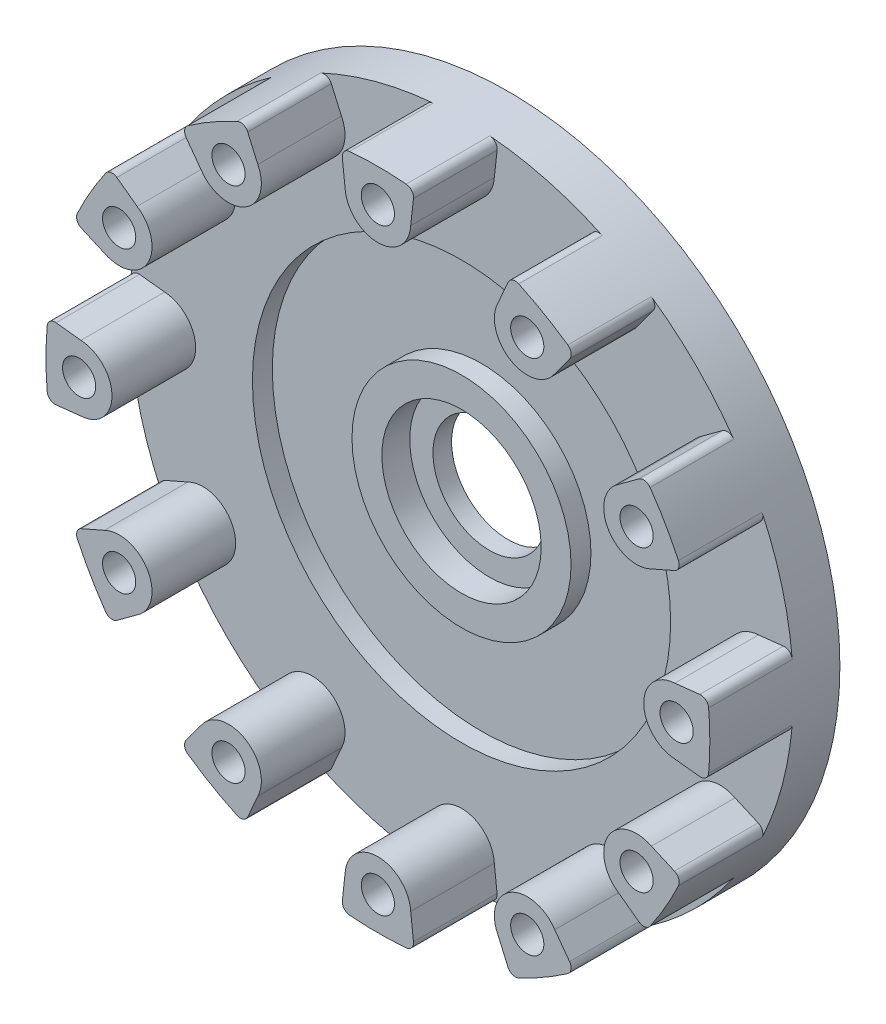
from build123d import *

# Parameters (mm, degrees)
SKETCH1_R           = 50
BOSS_EXTRUDE1_DEPTH = 7
SKETCH2_R           = 2.5
BOSS_EXTRUDE2_DEPTH = 12.6
CIRPATTERN1_COUNT   = 12
SKETCH3_R           = 12
CUT_EXTRUDE1_DEPTH  = 8
SKETCH4_R           = 31.5
SKETCH4_R_2         = 16.5
CUT_EXTRUDE2_DEPTH  = 3
BOSS_EXTRUDE3_START = -4.2
SKETCH5_R           = 12
SKETCH5_R_2         = 8.5
BOSS_EXTRUDE3_DEPTH = 2.8


with BuildPart() as part:
    # Sketch1 → Boss-Extrude1 (new body)
    with BuildSketch(Plane.XY):
        Circle(SKETCH1_R)
    extrude(amount=-BOSS_EXTRUDE1_DEPTH)

    # Sketch2 → Boss-Extrude2 (add)
    with BuildSketch(Plane.XY):
        with BuildLine():
            Line((44.72775, 4.942507454), (48.490092946, 5.358254011))
            ThreePointArc((48.490092946, 5.358254011), (49.383550497, 5.092810123), (49.817513468, 4.267944684))
            ThreePointArc((49.817513468, 4.267944684), (50, 0), (49.817513468, -4.267944684))
            ThreePointArc((49.817513468, -4.267944684), (49.383550497, -5.092810123), (48.490092946, -5.358254011))
            Line((48.490092946, -5.358254011), (44.72775, -4.942507454))
            ThreePointArc((44.72775, -4.942507454), (40.05, 0), (44.72775, 4.942507454))
        make_face()
        with Locations((45, 0)):
            Circle(SKETCH2_R, mode=Mode.SUBTRACT)
    boss_extrude2 = extrude(amount=BOSS_EXTRUDE2_DEPTH)

    # CirPattern1: Boss-Extrude2 ×12 about axis
    cirpattern1_axis = Axis((0, 0, 0), (0, 0, 1))
    for i in range(1, CIRPATTERN1_COUNT):
        add(boss_extrude2.rotate(cirpattern1_axis, i * 360 / CIRPATTERN1_COUNT))

    # Sketch3 → Cut-Extrude1 (cut, through all)
    with BuildSketch(Plane.XY):
        Circle(SKETCH3_R)
    extrude(amount=-CUT_EXTRUDE1_DEPTH, mode=Mode.SUBTRACT)

    # Sketch4 → Cut-Extrude2 (cut)
    with BuildSketch(Plane.XY):
        Circle(SKETCH4_R)
        Circle(SKETCH4_R_2, mode=Mode.SUBTRACT)
    extrude(amount=-CUT_EXTRUDE2_DEPTH, mode=Mode.SUBTRACT)

    # Sketch5 → Boss-Extrude3 (add)
    with BuildSketch(Plane.XY.offset(BOSS_EXTRUDE3_START)):
        Circle(SKETCH5_R)
        Circle(SKETCH5_R_2, mode=Mode.SUBTRACT)
    extrude(amount=-BOSS_EXTRUDE3_DEPTH)


solid = part.part
